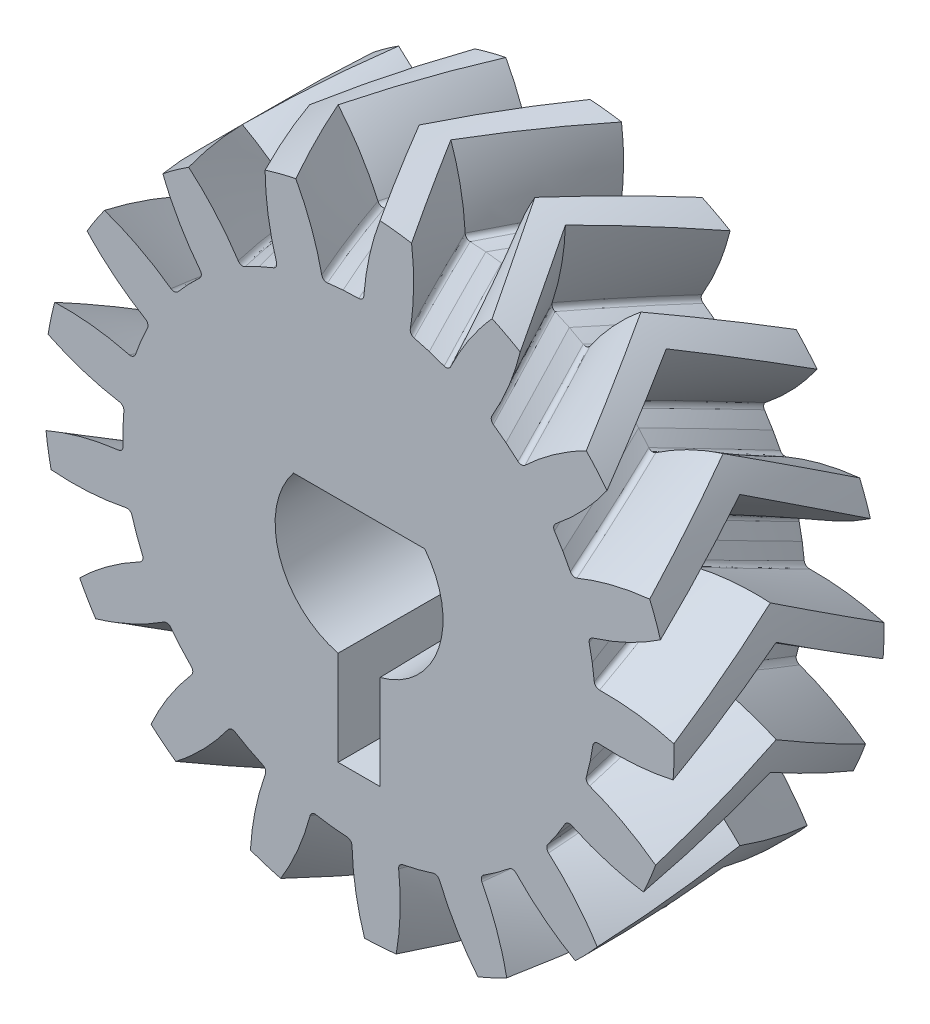
from build123d import *

# Parameters (mm, degrees)
SKETCH1_R              = 6
BOSS_EXTRUDE1_DEPTH    = 2
CUT_SWEEP1_PITCH       = 60
CUT_SWEEP1_HEIGHT      = 3
CUT_SWEEP1_RADIUS      = 6
CUT_SWEEP1_START_ANGLE = 180
CIRPATTERN1_COUNT      = 17
CUT_EXTRUDE1_DEPTH     = 10.380833482
CUT_EXTRUDE1_DRAFT     = -0.75


with BuildPart() as part:
    # Sketch1 → Boss-Extrude1 (new body)
    with BuildSketch(Plane.XY):
        Circle(SKETCH1_R)
    extrude(amount=BOSS_EXTRUDE1_DEPTH)

    # Cut-Sweep1: sweep along a helix
    with BuildLine() as cut_sweep1_path:
        add(Helix(CUT_SWEEP1_PITCH, CUT_SWEEP1_HEIGHT, CUT_SWEEP1_RADIUS, center=(0, 0, 2), direction=(0, 0, -1), mode=Mode.PRIVATE).rotate(Axis((0, 0, 2), (0, 0, -1)), CUT_SWEEP1_START_ANGLE))
    # Sketch3 → Cut-Sweep1 (sweep, cut)
    with BuildSketch(Plane.XY.offset(2)):
        with BuildLine():
            Line((4.5, 0), (4.489988864, 0.3))
            ThreePointArc((4.489988864, 0.3), (4.513311848, 0.367593757), (4.575810406, 0.402332895))
            ThreePointArc((4.575810406, 0.402332895), (5.573986132, 0.651654018), (6.5, 1.1))
            Line((6.5, 1.1), (6.5, -1.1))
            ThreePointArc((6.5, -1.1), (5.573986132, -0.651654018), (4.575810406, -0.402332895))
            ThreePointArc((4.575810406, -0.402332895), (4.513311848, -0.367593757), (4.489988864, -0.3))
            Line((4.489988864, -0.3), (4.5, 0))
        make_face()
    cut_sweep1 = sweep(path=cut_sweep1_path.line, is_frenet=True, mode=Mode.SUBTRACT)

    # CirPattern1: Cut-Sweep1 ×17 about axis
    cirpattern1_axis = Axis((0, 0, 2), (0, 0, 1))
    for i in range(1, CIRPATTERN1_COUNT):
        add(cut_sweep1.rotate(cirpattern1_axis, i * 360 / CIRPATTERN1_COUNT), mode=Mode.SUBTRACT)

    # Mirror1: part across plane


with BuildPart() as part_1:
    add(part.part)
    add(part.part.mirror(Plane.XY.offset(2)))


with BuildPart() as cut_extrude1_tool:
    # Sketch4 → Cut-Extrude1 (with draft: the straight prism first)
    with BuildSketch(Plane.XY.offset(4)):
        with BuildLine():
            ThreePointArc((-1.25, 0.998749218), (-1.517770674, -0.506332087), (-0.4, -1.549193338))
            Line((-0.4, -1.549193338), (-0.4, -3.349193338))
            Line((-0.4, -3.349193338), (0.4, -3.349193338))
            Line((0.4, -3.349193338), (0.4, -1.549193338))
            ThreePointArc((0.4, -1.549193338), (1.517770674, -0.506332087), (1.25, 0.998749218))
            Line((1.25, 0.998749218), (-1.25, 0.998749218))
        make_face()
    extrude(amount=-CUT_EXTRUDE1_DEPTH)
    # Cut-Extrude1: the draft: its side faces are tilted about the plane it starts from
    cut_extrude1_sides = [cut_extrude1_tool.faces().sort_by_distance(p)[0] for p in [
        (0, 0.998749218, -1.190416741),
        (-1.517770674, -0.506332087, -1.190416741),
        (-0.4, -2.449193338, -1.190416741),
        (0, -3.349193338, -1.190416741),
        (0.4, -2.449193338, -1.190416741),
        (1.517770674, -0.506332087, -1.190416741),
    ]]
    draft(cut_extrude1_sides, Plane.XY.offset(4), CUT_EXTRUDE1_DRAFT)


with BuildPart() as part_2:
    add(part_1.part)

    # Cut-Extrude1: cut by cut_extrude1_tool
    add(cut_extrude1_tool.part, mode=Mode.SUBTRACT)


solid = part_2.part
